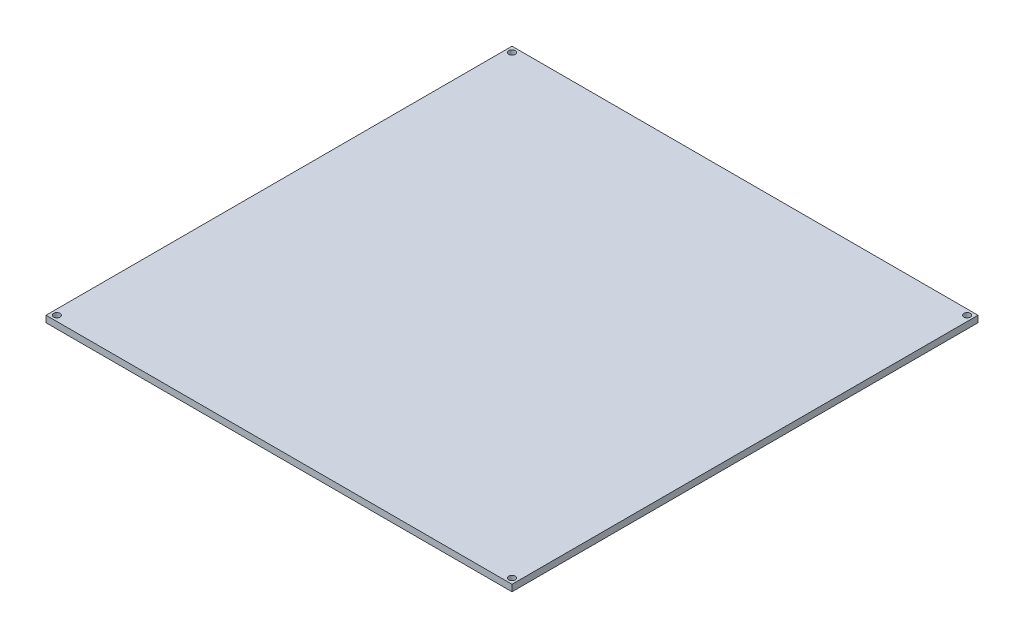
from build123d import *

# Parameters (mm, degrees)
CROQUIS1_W              = 214
CROQUIS1_H              = 214
SALIENTE_EXTRUIR1_DEPTH = 3
CROQUIS2_R              = 1.5
CORTAR_EXTRUIR1_DEPTH   = 3


with BuildPart() as part:
    # Croquis1 → Saliente-Extruir1 (new body)
    with BuildSketch(Plane(origin=(0, 0, 0), x_dir=(1, 0, 0), z_dir=(0, 1, 0))):
        with Locations((107, 107)):
            Rectangle(CROQUIS1_W, CROQUIS1_H)
    extrude(amount=SALIENTE_EXTRUIR1_DEPTH)

    # Croquis2 → Cortar-Extruir1 (cut)
    with BuildSketch(Plane(origin=(0, 3, 0), x_dir=(1, 0, 0), z_dir=(0, 1, 0))):
        with Locations((2.5, 211.5)):
            Circle(CROQUIS2_R)
        with Locations((2.5, 2.5)):
            Circle(CROQUIS2_R)
        with Locations((211.5, 2.5)):
            Circle(CROQUIS2_R)
        with Locations((211.5, 211.5)):
            Circle(CROQUIS2_R)
    extrude(amount=-CORTAR_EXTRUIR1_DEPTH, mode=Mode.SUBTRACT)


solid = part.part
